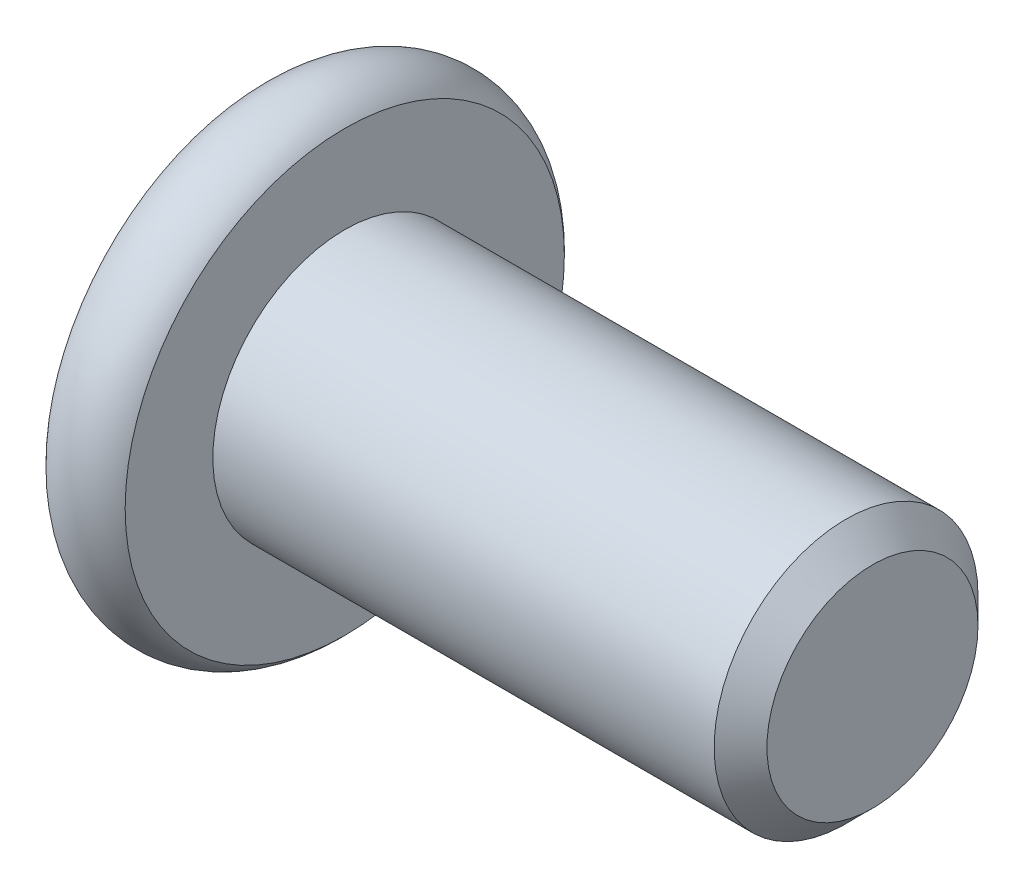
from build123d import *

# Parameters (mm, degrees)
SKETCH2_R           = 2.5
BOSS_EXTRUDE1_DEPTH = 10
CHAMFER1_SIZE       = 0.5
CUT_EXTRUDE1_DEPTH  = 2.3
SKETCH8_R           = 1.782050808
CUT_EXTRUDE2_DEPTH  = 1
CUT_EXTRUDE2_TAPER  = 45


with BuildPart() as part:
    # Sketch2 → Boss-Extrude1 (new body)
    with BuildSketch(Plane(origin=(0, 0, 0), x_dir=(0, 0, -1), z_dir=(1, 0, 0))):
        Circle(SKETCH2_R)
    extrude(amount=-BOSS_EXTRUDE1_DEPTH)

    # Chamfer1
    chamfer1_edges = [part.edges().sort_by_distance(p)[0] for p in [
        (0, 0, 2.5),
    ]]
    chamfer(chamfer1_edges, length=CHAMFER1_SIZE)

    # Sketch6 → Revolve1 (revolve)
    with BuildSketch(Plane.XY):
        with BuildLine():
            Line((-11.5, 0), (-11.5, 4.161437828))
            ThreePointArc((-11.5, 4.161437828), (-10.75, 4.5), (-10, 4.161437828))
            Line((-10, 4.161437828), (-10, 0))
            Line((-10, 0), (-11.5, 0))
        make_face()
    revolve(axis=Axis((-10, 0, 0), (-1, 0, 0)))

    # Sketch7 → Cut-Extrude1 (cut)
    with BuildSketch(Plane.ZY.offset(11.5)):
        Polygon((0, 1.732050808), (-1.5, 0.866025404), (-1.5, -0.866025404), (0, -1.732050808), (1.5, -0.866025404), (1.5, 0.866025404), align=None)
    extrude(amount=-CUT_EXTRUDE1_DEPTH, mode=Mode.SUBTRACT)

    # Sketch8 → Cut-Extrude2 (cut)
    with BuildSketch(Plane.ZY.offset(11.5)):
        Circle(SKETCH8_R)
    extrude(amount=-CUT_EXTRUDE2_DEPTH, taper=CUT_EXTRUDE2_TAPER, mode=Mode.SUBTRACT)


solid = part.part
